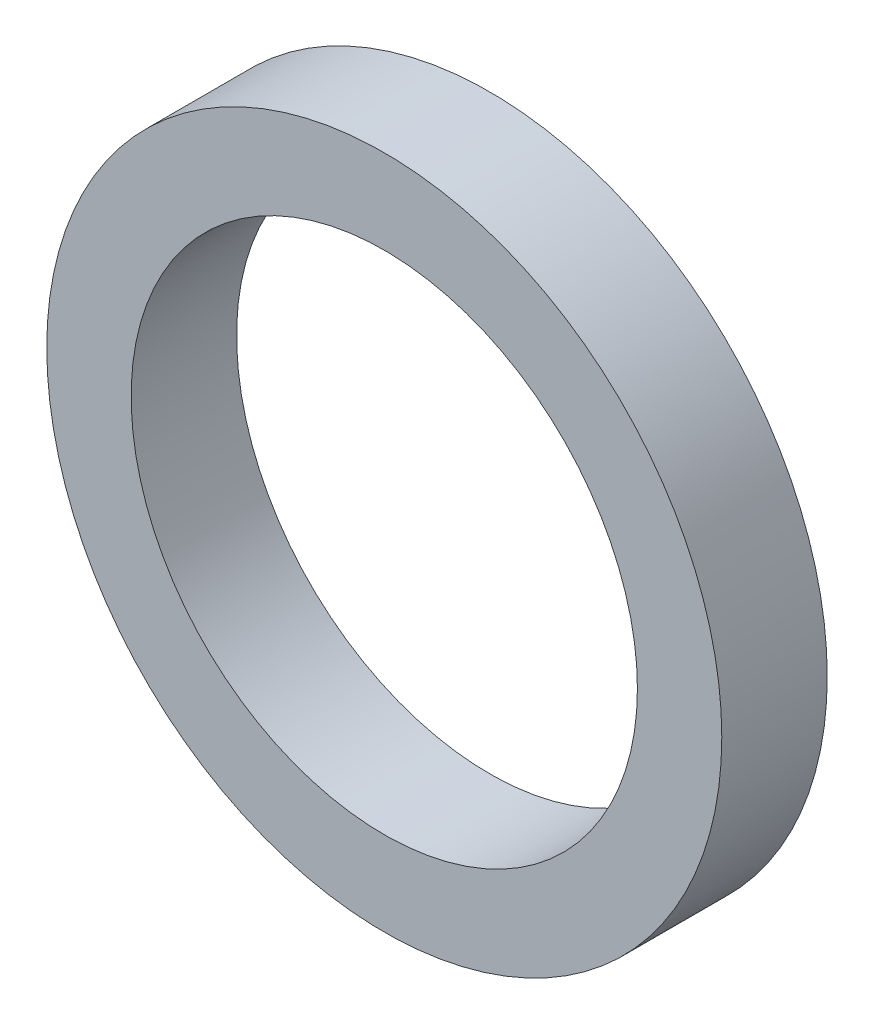
from build123d import *

# Parameters (mm, degrees)
SKETCH1_R           = 12.7
SKETCH1_R_2         = 9.525
BOSS_EXTRUDE1_DEPTH = 3.96748


with BuildPart() as part:
    # Sketch1 → Boss-Extrude1 (new body)
    with BuildSketch(Plane.XY):
        Circle(SKETCH1_R)
        Circle(SKETCH1_R_2, mode=Mode.SUBTRACT)
    extrude(amount=BOSS_EXTRUDE1_DEPTH)


solid = part.part
